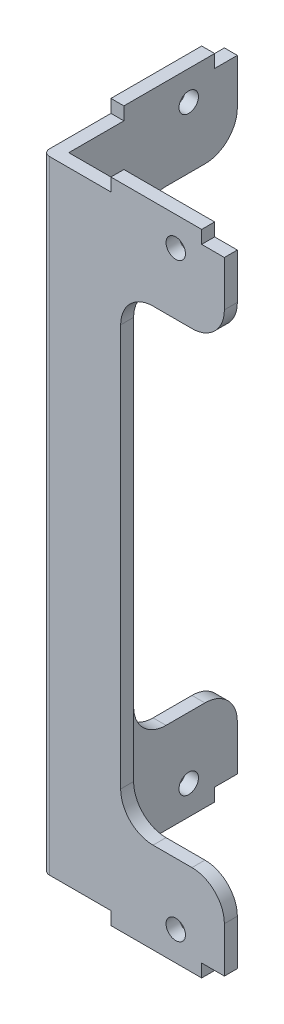
from build123d import *

# Parameters (mm, degrees)
SKETCH1_R           = 1.5
BOSS_EXTRUDE1_DEPTH = 2
SKETCH2_R           = 1.5
BOSS_EXTRUDE2_DEPTH = 2
FILLET1_R           = 1


with BuildPart() as part:
    # Sketch1 → Boss-Extrude1 (new body)
    with BuildSketch(Plane.XY):
        with BuildLine():
            Line((0, 96), (0, 0))
            Line((0, 0), (10.5, 0))
            Line((10.5, 0), (10.5, -2))
            Line((10.5, -2), (24.5, -2))
            Line((24.5, -2), (24.5, 0))
            Line((24.5, 0), (28, 0))
            Line((28, 0), (28, 7))
            ThreePointArc((28, 7), (26.535533906, 10.535533906), (23, 12))
            Line((23, 12), (17, 12))
            ThreePointArc((17, 12), (13.464466094, 13.464466094), (12, 17))
            Line((12, 17), (12, 79))
            ThreePointArc((12, 79), (13.464466094, 82.535533906), (17, 84))
            Line((17, 84), (23, 84))
            ThreePointArc((23, 84), (26.535533906, 85.464466094), (28, 89))
            Line((28, 89), (28, 96))
            Line((28, 96), (24.5, 96))
            Line((24.5, 96), (24.5, 98))
            Line((24.5, 98), (10.5, 98))
            Line((10.5, 98), (10.5, 96))
            Line((10.5, 96), (0, 96))
        make_face()
        with Locations((20.5, 2.5)):
            Circle(SKETCH1_R, mode=Mode.SUBTRACT)
        with Locations((20.5, 93.5)):
            Circle(SKETCH1_R, mode=Mode.SUBTRACT)
    extrude(amount=BOSS_EXTRUDE1_DEPTH)

    # Sketch2 → Boss-Extrude2 (add)
    with BuildSketch(Plane.ZY):
        with BuildLine():
            Line((0, 96), (-8.5, 96))
            Line((-8.5, 96), (-8.5, 98))
            Line((-8.5, 98), (-22.5, 98))
            Line((-22.5, 98), (-22.5, 96))
            Line((-22.5, 96), (-26, 96))
            Line((-26, 96), (-26, 89))
            ThreePointArc((-26, 89), (-24.535533906, 85.464466094), (-21, 84))
            Line((-21, 84), (-15, 84))
            ThreePointArc((-15, 84), (-11.464466094, 82.535533906), (-10, 79))
            Line((-10, 79), (-10, 17))
            ThreePointArc((-10, 17), (-11.464466094, 13.464466094), (-15, 12))
            Line((-15, 12), (-21, 12))
            ThreePointArc((-21, 12), (-24.535533906, 10.535533906), (-26, 7))
            Line((-26, 7), (-26, 0))
            Line((-26, 0), (-22.5, 0))
            Line((-22.5, 0), (-22.5, -2))
            Line((-22.5, -2), (-8.5, -2))
            Line((-8.5, -2), (-8.5, 0))
            Line((-8.5, 0), (0, 0))
            Line((0, 0), (0, 96))
        make_face()
        with Locations((-18.5, 93.5)):
            Circle(SKETCH2_R, mode=Mode.SUBTRACT)
        with Locations((-18.5, 2.5)):
            Circle(SKETCH2_R, mode=Mode.SUBTRACT)
    extrude(amount=-BOSS_EXTRUDE2_DEPTH)

    # Fillet1
    fillet1_edges = [part.edges().sort_by_distance(p)[0] for p in [
        (0, 48, 2),
    ]]
    fillet(fillet1_edges, radius=FILLET1_R)


solid = part.part
